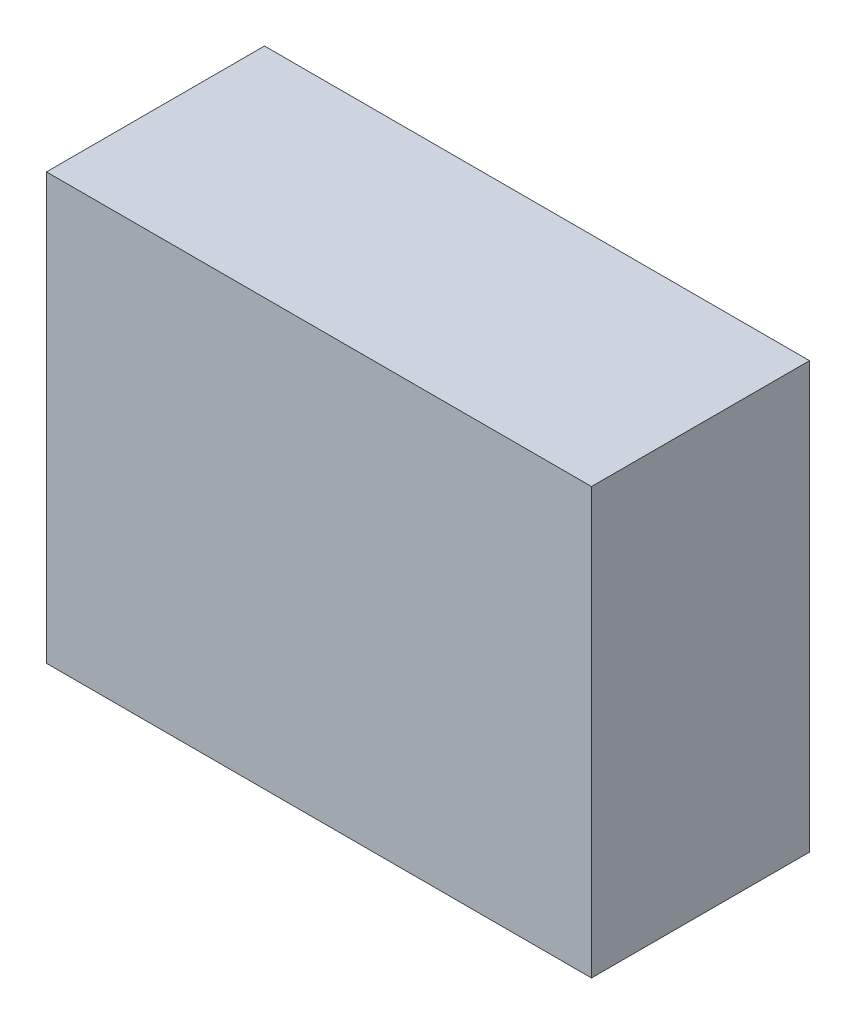
from build123d import *

# Parameters (mm, degrees)
SKETCH1_W           = 4.2
SKETCH1_H           = 8.2
BOSS_EXTRUDE1_DEPTH = 10.5


with BuildPart() as part:
    # Sketch1 → Boss-Extrude1 (new body)
    with BuildSketch(Plane(origin=(0, 0, 0), x_dir=(0, 0, -1), z_dir=(1, 0, 0))):
        Rectangle(SKETCH1_W, SKETCH1_H)
    extrude(amount=BOSS_EXTRUDE1_DEPTH)


solid = part.part
